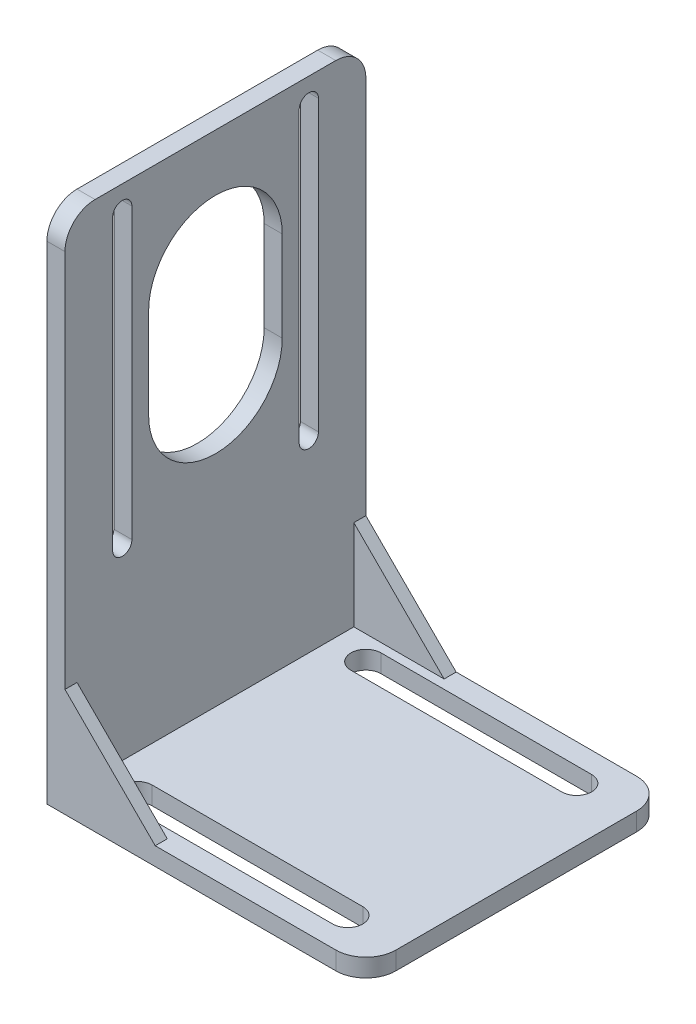
from build123d import *

# Parameters (mm, degrees)
SKETCH_1_W          = 53
SKETCH_1_H          = 50
EXTRUDE_1_DEPTH     = 3
CUT_EXTRUDE_1_DEPTH = 4
SKETCH_3_W          = 3
SKETCH_3_H          = 50
EXTRUDE_2_DEPTH     = 83
CUT_EXTRUDE_2_DEPTH = 54
EXTRUDE_3_DEPTH     = 2
EXTRUDE_4_DEPTH     = 2
FILLET_1_R          = 5


with BuildPart() as part:
    # 草图1 → 凸台-拉伸1 (new body)
    with BuildSketch(Plane(origin=(0, 0, 0), x_dir=(1, 0, 0), z_dir=(0, 1, 0))):
        Rectangle(SKETCH_1_W, SKETCH_1_H)
    extrude(amount=EXTRUDE_1_DEPTH)

    # 草图2 → 切除-拉伸1 (cut, through all)
    with BuildSketch(Plane(origin=(0, 3, 0), x_dir=(1, 0, 0), z_dir=(0, 1, 0))):
        with BuildLine():
            Line((-17.5, 21.514185104), (17.5, 21.514185104))
            ThreePointArc((17.5, 21.514185104), (20, 19.014185104), (17.5, 16.514185104))
            Line((17.5, 16.514185104), (-17.5, 16.514185104))
            ThreePointArc((-17.5, 16.514185104), (-20, 19.014185104), (-17.5, 21.514185104))
        make_face()
        with BuildLine():
            Line((-17.5, -21.514185104), (17.5, -21.514185104))
            ThreePointArc((17.5, -21.514185104), (20, -19.014185104), (17.5, -16.514185104))
            Line((17.5, -16.514185104), (-17.5, -16.514185104))
            ThreePointArc((-17.5, -16.514185104), (-20, -19.014185104), (-17.5, -21.514185104))
        make_face()
    extrude(amount=-CUT_EXTRUDE_1_DEPTH, mode=Mode.SUBTRACT)

    # 草图3 → 凸台-拉伸2 (add)
    with BuildSketch(Plane(origin=(0, 3, 0), x_dir=(1, 0, 0), z_dir=(0, 1, 0))):
        with Locations((-25, 0)):
            Rectangle(SKETCH_3_W, SKETCH_3_H)
    extrude(amount=EXTRUDE_2_DEPTH)

    # 草图4 → 切除-拉伸2 (cut, through all)
    with BuildSketch(Plane.ZY.offset(26.5)):
        with BuildLine():
            Line((-13.921207139, 82), (-13.921207139, 34))
            ThreePointArc((-13.921207139, 34), (-15.521207139, 32.4), (-17.121207139, 34))
            Line((-17.121207139, 34), (-17.121207139, 82))
            ThreePointArc((-17.121207139, 82), (-15.521207139, 83.6), (-13.921207139, 82))
        make_face()
        with BuildLine():
            Line((11.1, 65.5), (11.1, 50.5))
            ThreePointArc((11.1, 50.5), (0, 39.4), (-11.1, 50.5))
            Line((-11.1, 50.5), (-11.1, 65.5))
            ThreePointArc((-11.1, 65.5), (0, 76.6), (11.1, 65.5))
        make_face()
        with BuildLine():
            Line((17.078792861, 82), (17.078792861, 34))
            ThreePointArc((17.078792861, 34), (15.478792861, 32.4), (13.878792861, 34))
            Line((13.878792861, 34), (13.878792861, 82))
            ThreePointArc((13.878792861, 82), (15.478792861, 83.6), (17.078792861, 82))
        make_face()
    extrude(amount=-CUT_EXTRUDE_2_DEPTH, mode=Mode.SUBTRACT)

    # 草图5 → 凸台-拉伸3 (add)
    with BuildSketch(Plane.XY.offset(25)):
        Polygon((-23.5, 18), (-8.5, 3), (-23.5, 3), align=None)
    extrude(amount=-EXTRUDE_3_DEPTH)

    # 草图7 → 凸台-拉伸4 (add)
    with BuildSketch(Plane(origin=(0, 0, -25), x_dir=(-1, 0, 0), z_dir=(0, 0, -1))):
        Polygon((23.5, 18), (8.5, 3), (23.5, 3), align=None)
    extrude(amount=-EXTRUDE_4_DEPTH)

    # 圆角1
    fillet_1_edges = [part.edges().sort_by_distance(p)[0] for p in [
        (-25, 86, 25),
        (-25, 86, -25),
        (26.5, 1.5, 25),
        (26.5, 1.5, -25),
    ]]
    fillet(fillet_1_edges, radius=FILLET_1_R)


solid = part.part
